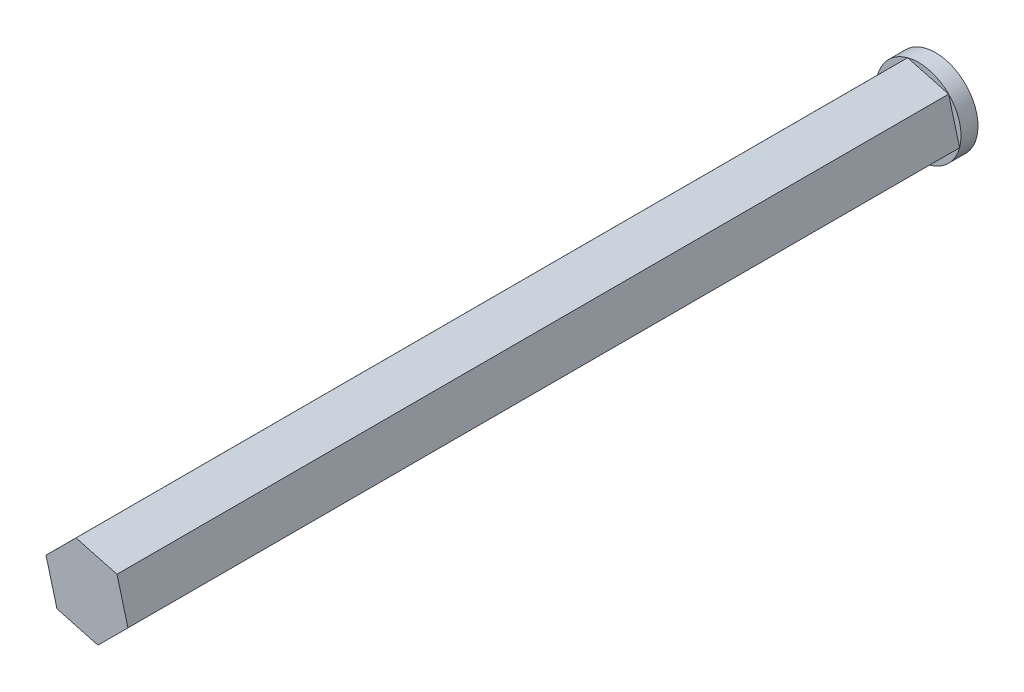
from build123d import *

# Parameters (mm, degrees)
CROQUIS1_R              = 2.5
SALIENTE_EXTRUIR2_DEPTH = 1
SALIENTE_EXTRUIR3_DEPTH = 49


with BuildPart() as part:
    # Croquis1 → Saliente-Extruir2 (new body)
    with BuildSketch(Plane.XY):
        with Locations((-3.465701934, 4.477303942)):
            Circle(CROQUIS1_R)
    extrude(amount=SALIENTE_EXTRUIR2_DEPTH)

    # Croquis2 → Saliente-Extruir3 (add)
    with BuildSketch(Plane.XY.offset(1)):
        Polygon((-1.051265683, 3.828846087), (-1.696902833, 6.244038144), (-4.111339084, 6.892495999), (-5.880138185, 5.125761797), (-5.234501035, 2.71056974), (-2.820064784, 2.062111885), align=None)
    extrude(amount=SALIENTE_EXTRUIR3_DEPTH)


solid = part.part
